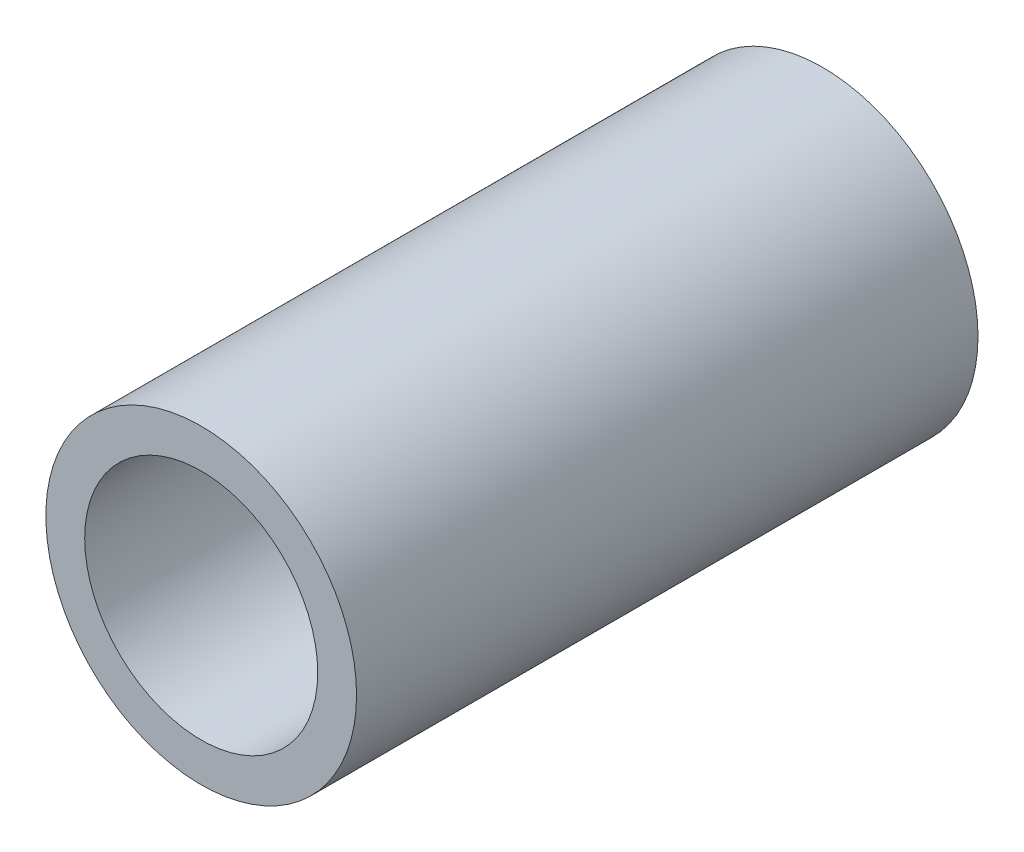
from build123d import *

# Parameters (mm, degrees)
SKETCH_1_R      = 4
SKETCH_1_R_2    = 3
EXTRUDE_1_DEPTH = 16


with BuildPart() as part:
    # 草图1 → 凸台-拉伸1 (new body)
    with BuildSketch(Plane.XY):
        Circle(SKETCH_1_R)
        Circle(SKETCH_1_R_2, mode=Mode.SUBTRACT)
    extrude(amount=EXTRUDE_1_DEPTH)


solid = part.part
